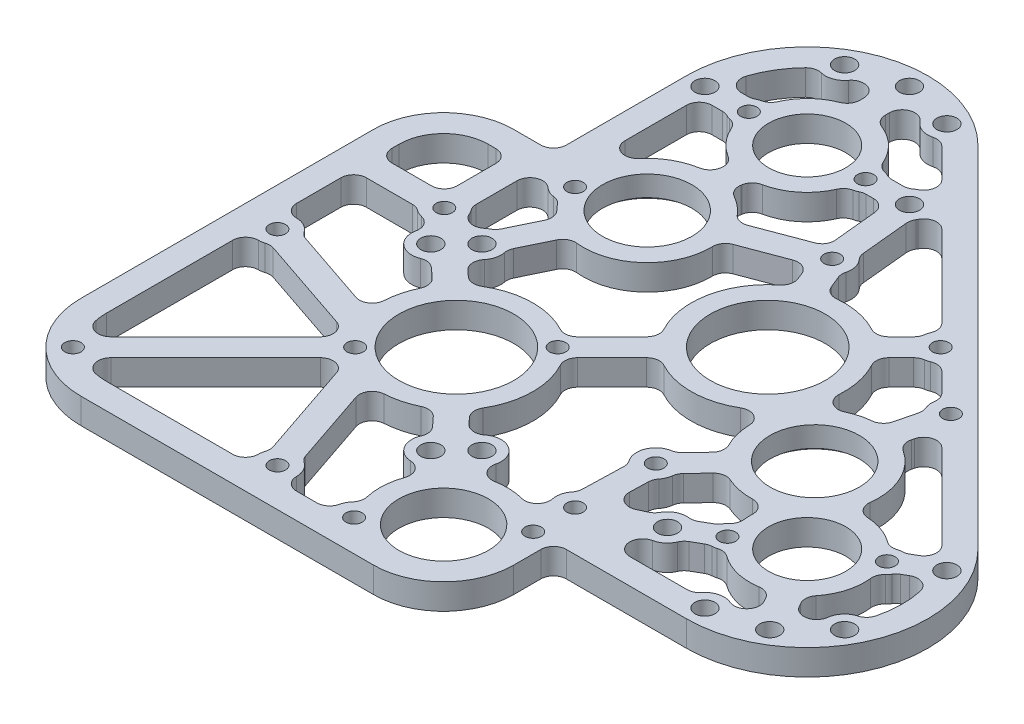
from build123d import *

# Parameters (mm, degrees)
BOSS_EXTRUDE1_DEPTH              = 6.35
SKETCH2_W                        = 83.815021508
SKETCH2_H                        = 6.35
BOSS_EXTRUDE2_DEPTH              = 27.309978492
SKETCH3_W                        = 111.125
SKETCH3_H                        = 6.35
BOSS_EXTRUDE3_DEPTH              = 27.309978492
CUT_EXTRUDE1_DEPTH               = 7.35
CUT_EXTRUDE2_DEPTH               = 7.35
CUT_EXTRUDE3_DEPTH               = 7.35
CUT_EXTRUDE4_DEPTH               = 7.35
CUT_EXTRUDE5_DEPTH               = 7.35
CUT_EXTRUDE6_DEPTH               = 7.35
CUT_EXTRUDE7_DEPTH               = 7.35
CUT_EXTRUDE8_DEPTH               = 7.35
CUT_EXTRUDE9_DEPTH               = 7.35
CUT_EXTRUDE10_DEPTH              = 7.35
CUT_EXTRUDE11_DEPTH              = 7.35
CUT_EXTRUDE12_DEPTH              = 7.35
CUT_EXTRUDE13_DEPTH              = 7.35
SKETCH17_W                       = 16.166007452
SKETCH17_H                       = 16.00062303
CUT_EXTRUDE14_DEPTH              = 7.35
CUT_EXTRUDE15_DEPTH              = 7.35
CUT_EXTRUDE16_DEPTH              = 7.35
CUT_EXTRUDE17_DEPTH              = 7.35
CUT_EXTRUDE18_DEPTH              = 7.35
CUT_EXTRUDE19_DEPTH              = 1.27
F_7_8_0_875_DIAMETER_HOLE1_D     = 22.225
F_7_8_0_875_DIAMETER_HOLE1_DEPTH = 5.08
HOLE1_D                          = 19.177
HOLE1_DEPTH                      = 6.35
F_9_0_196_DIAMETER_HOLE1_D       = 4.9784
F_9_0_196_DIAMETER_HOLE1_DEPTH   = 6.35
F_21_0_159_DIAMETER_HOLE1_D      = 4.0386
F_21_0_159_DIAMETER_HOLE1_DEPTH  = 5.08
F_21_0_159_DIAMETER_HOLE2_D      = 4.0386
F_21_0_159_DIAMETER_HOLE2_DEPTH  = 6.35
F_7_8_0_875_DIAMETER_HOLE2_D     = 22.225
F_7_8_0_875_DIAMETER_HOLE2_DEPTH = 6.35
HOLE2_D                          = 28.575
HOLE2_DEPTH                      = 6.35
F_1_12_TAPPED_HOLE1_D            = 22.225
F_1_12_TAPPED_HOLE1_DEPTH        = 6.35
F_1_12_TAPPED_HOLE1_CBORE_D      = 25.4
F_1_12_TAPPED_HOLE1_CBORE_DEPTH  = 1.27
FILLET1_R                        = 3.175
FILLET2_R                        = 11.061747228
FILLET3_R                        = 17.411747228
FILLET4_R                        = 21.022692091
F_21_0_159_DIAMETER_HOLE3_D      = 4.0386


with BuildPart() as part:
    # Sketch1 → Boss-Extrude1 (new body)
    with BuildSketch(Plane(origin=(0, 3.175, 0), x_dir=(1, 0, 0), z_dir=(0, 1, 0))):
        with BuildLine():
            Line((-29.840021508, 86.969452862), (-29.840021508, -29.840021508))
            Line((-29.840021508, -29.840021508), (86.969452862, -29.840021508))
            ThreePointArc((86.969452862, -29.840021508), (114.685838837, -11.320524479), (108.182656297, 21.373181928))
            Line((108.182656297, 21.373181928), (21.373181928, 108.182656297))
            ThreePointArc((21.373181928, 108.182656297), (-11.320524479, 114.685838837), (-29.840021508, 86.969452862))
        make_face()
    extrude(amount=-BOSS_EXTRUDE1_DEPTH)

    # Sketch2 → Boss-Extrude2 (add)
    with BuildSketch(Plane.XY.offset(29.840021508)):
        with Locations((12.067489246, 0)):
            Rectangle(SKETCH2_W, SKETCH2_H)
    extrude(amount=BOSS_EXTRUDE2_DEPTH)

    # Sketch3 → Boss-Extrude3 (add)
    with BuildSketch(Plane.ZY.offset(29.840021508)):
        with Locations((1.5875, 0)):
            Rectangle(SKETCH3_W, SKETCH3_H)
    extrude(amount=BOSS_EXTRUDE3_DEPTH)

    # Sketch4 → Cut-Extrude1 (cut, through all)
    with BuildSketch(Plane(origin=(0, 3.175, 0), x_dir=(-1, 0, 0), z_dir=(0, 1, 0))):
        with BuildLine():
            Line((-29.065314853, -83.745476551), (-30.455840544, -69.522624049))
            ThreePointArc((-30.455840544, -69.522624049), (-32.264427746, -66.824529621), (-31.922480515, -63.594394438))
            Line((-31.922480515, -63.594394438), (-34.508853412, -57.259190575))
            ThreePointArc((-34.508853412, -57.259190575), (-42.433061391, -57.343409563), (-49.705896748, -54.196024809))
            Line((-49.705896748, -54.196024809), (-55.38295153, -59.87307959))
            ThreePointArc((-55.38295153, -59.87307959), (-55.727962262, -61.935940392), (-56.923524748, -63.652057356))
            Line((-56.923524748, -63.652057356), (-34.906645585, -85.668936518))
            ThreePointArc((-34.906645585, -85.668936518), (-32.152081027, -86.557725422), (-29.82094033, -84.842104637))
            ThreePointArc((-29.82094033, -84.842104637), (-29.481648445, -84.267248015), (-29.065314853, -83.745476551))
        make_face()
    extrude(amount=-CUT_EXTRUDE1_DEPTH, mode=Mode.SUBTRACT)

    # Sketch5 → Cut-Extrude2 (cut, through all)
    with BuildSketch(Plane(origin=(0, 3.175, 0), x_dir=(-1, 0, 0), z_dir=(0, 1, 0))):
        with BuildLine():
            Line((-96.684211501, 10.316477055), (-98.336356147, 13.178075522))
            ThreePointArc((-98.336356147, 13.178075522), (-101.722511979, 14.701115781), (-104.238191329, 11.970353917))
            ThreePointArc((-104.238191329, 11.970353917), (-105.912215429, 8.885878174), (-109.244761312, 7.785657634))
            ThreePointArc((-109.244761312, 7.785657634), (-110.566098558, 1.427727994), (-110.10840545, -5.049904169))
            ThreePointArc((-110.10840545, -5.049904169), (-108.295106019, -7.293181843), (-105.414513295, -7.143064889))
            Line((-105.414513295, -7.143064889), (-103.221340735, -5.876836121))
            ThreePointArc((-103.221340735, -5.876836121), (-102.266814576, -4.495799982), (-100.82964184, -3.628092927))
            ThreePointArc((-100.82964184, -3.628092927), (-100.664608822, 3.911306251), (-96.684211501, 10.316477055))
        make_face()
    extrude(amount=-CUT_EXTRUDE2_DEPTH, mode=Mode.SUBTRACT)

    # Sketch6 → Cut-Extrude3 (cut, through all)
    with BuildSketch(Plane(origin=(0, 3.175, 0), x_dir=(-1, 0, 0), z_dir=(0, 1, 0))):
        with BuildLine():
            Line((16.061248626, -10.243963713), (22.052702088, -15.662227437))
            ThreePointArc((22.052702088, -15.662227437), (27.684230049, -14.871040879), (30.058808712, -20.038386379))
            ThreePointArc((30.058808712, -20.038386379), (30.496077117, -22.417536581), (32.482405731, -23.798137167))
            ThreePointArc((32.482405731, -23.798137167), (33.861760631, -24.337429525), (35.008750462, -25.27437697))
            Line((35.008750462, -25.27437697), (50.8, -25.27437697))
            Line((50.8, -25.27437697), (50.8, -6.724757914))
            ThreePointArc((50.8, -6.724757914), (46.591275424, -7.823958996), (43.244919278, -5.04483933))
            Line((43.244919278, -5.04483933), (23.20612022, 1.735140088))
            ThreePointArc((23.20612022, 1.735140088), (20.412532978, 1.359425204), (19.018755694, -1.090610762))
            ThreePointArc((19.018755694, -1.090610762), (18.127262434, -5.8570348), (16.061248626, -10.243963713))
        make_face()
    extrude(amount=-CUT_EXTRUDE3_DEPTH, mode=Mode.SUBTRACT)

    # Sketch7 → Cut-Extrude4 (cut, through all)
    with BuildSketch(Plane(origin=(0, 3.175, 0), x_dir=(-1, 0, 0), z_dir=(0, 1, 0))):
        with BuildLine():
            Line((-24.259462149, -96.316119955), (-15.54353696, -105.032045144))
            ThreePointArc((-15.54353696, -105.032045144), (-12.080764428, -104.268175897), (-9.049978492, -106.108998118))
            ThreePointArc((-9.049978492, -106.108998118), (-5.505955335, -107.216067589), (-3.334978492, -104.203998118))
            Line((-3.334978492, -104.203998118), (-3.334978492, -100.899708827))
            ThreePointArc((-3.334978492, -100.899708827), (-9.984690796, -97.342865241), (-13.897312756, -90.896067632))
            ThreePointArc((-13.897312756, -90.896067632), (-15.575806101, -90.863204873), (-17.092979596, -90.144452862))
            Line((-17.092979596, -90.144452862), (-22.010220578, -90.144452862))
            ThreePointArc((-22.010220578, -90.144452862), (-22.669959149, -90.754845106), (-23.432630268, -91.230414699))
            ThreePointArc((-23.432630268, -91.230414699), (-25.148251052, -93.561555396), (-24.259462149, -96.316119955))
        make_face()
    extrude(amount=-CUT_EXTRUDE4_DEPTH, mode=Mode.SUBTRACT)

    # Sketch8 → Cut-Extrude5 (cut, through all)
    with BuildSketch(Plane(origin=(0, 3.175, 0), x_dir=(-1, 0, 0), z_dir=(0, 1, 0))):
        with BuildLine():
            Line((-28.629907712, -54.859086941), (-25.869683695, -61.620131289))
            Line((-25.869683695, -61.620131289), (-9.958043734, -55.623628588))
            ThreePointArc((-9.958043734, -55.623628588), (-5.003627435, -41.400778281), (9.599912876, -37.716715024))
            Line((9.599912876, -37.716715024), (14.64981546, -27.222026966))
            ThreePointArc((14.64981546, -27.222026966), (14.863395085, -23.129813767), (18.176462317, -20.718297514))
            Line((18.176462317, -20.718297514), (11.802062224, -14.953722856))
            ThreePointArc((11.802062224, -14.953722856), (0.478055111, -19.044000717), (-11.036913891, -15.527041951))
            Line((-11.036913891, -15.527041951), (-23.141940906, -27.632068966))
            ThreePointArc((-23.141940906, -27.632068966), (-19.994556151, -42.433061391), (-28.629907712, -54.859086941))
        make_face()
    extrude(amount=-CUT_EXTRUDE5_DEPTH, mode=Mode.SUBTRACT)

    # Sketch9 → Cut-Extrude6 (cut, through all)
    with BuildSketch(Plane(origin=(0, 3.175, 0), x_dir=(-1, 0, 0), z_dir=(0, 1, 0))):
        with BuildLine():
            Line((-66.570306617, 23.490021508), (-82.540129409, 23.490021508))
            ThreePointArc((-82.540129409, 23.490021508), (-85.134980242, 20.845011103), (-88.84025965, 20.860353917))
            ThreePointArc((-88.84025965, 20.860353917), (-92.463008471, 20.047092624), (-92.837094833, 16.353075522))
            Line((-92.837094833, 16.353075522), (-91.184950187, 13.491477055))
            ThreePointArc((-91.184950187, 13.491477055), (-83.647710894, 13.73601685), (-77.035883168, 10.109240047))
            ThreePointArc((-77.035883168, 10.109240047), (-75.565840448, 10.920014619), (-73.892564989, 11.056140451))
            Line((-73.892564989, 11.056140451), (-69.634088137, 13.514773208))
            ThreePointArc((-69.634088137, 13.514773208), (-68.334217118, 15.91339416), (-65.931147012, 17.205021508))
            ThreePointArc((-65.931147012, 17.205021508), (-63.411598416, 20.63624962), (-66.570306617, 23.490021508))
        make_face()
    extrude(amount=-CUT_EXTRUDE6_DEPTH, mode=Mode.SUBTRACT)

    # Sketch10 → Cut-Extrude7 (cut, through all)
    with BuildSketch(Plane(origin=(0, 3.175, 0), x_dir=(-1, 0, 0), z_dir=(0, 1, 0))):
        with BuildLine():
            Line((-60.582930959, -6.529869086), (-54.504223769, -0.14881941))
            ThreePointArc((-54.504223769, -0.14881941), (-54.153577144, 2.061993213), (-52.831648467, 3.868412347))
            Line((-52.831648467, 3.868412347), (-52.670582669, 9.638745034))
            ThreePointArc((-52.670582669, 9.638745034), (-54.090630257, 12.374049221), (-57.163109223, 12.615497253))
            Line((-57.163109223, 12.615497253), (-60.424579656, 11.126279242))
            ThreePointArc((-60.424579656, 11.126279242), (-62.790235694, 8.306874688), (-66.459088137, 8.015511894))
            Line((-66.459088137, 8.015511894), (-70.717564989, 5.556879137))
            ThreePointArc((-70.717564989, 5.556879137), (-71.672091147, 4.175842998), (-73.109263883, 3.308135943))
            ThreePointArc((-73.109263883, 3.308135943), (-72.69360414, -0.736866294), (-73.434293106, -4.735140418))
            ThreePointArc((-73.434293106, -4.735140418), (-66.816865189, -4.259479304), (-60.582930959, -6.529869086))
        make_face()
    extrude(amount=-CUT_EXTRUDE7_DEPTH, mode=Mode.SUBTRACT)

    # Sketch11 → Cut-Extrude8 (cut, through all)
    with BuildSketch(Plane(origin=(0, 3.175, 0), x_dir=(-1, 0, 0), z_dir=(0, 1, 0))):
        with BuildLine():
            Line((36.127307909, 50.8), (0.374757914, 50.8))
            ThreePointArc((0.374757914, 50.8), (1.560030882, 48.135772743), (0.970199293, 45.280063098))
            Line((0.970199293, 45.280063098), (9.398704369, 20.368907892))
            ThreePointArc((9.398704369, 20.368907892), (11.683715037, 18.294780227), (14.651287711, 19.141415771))
            Line((14.651287711, 19.141415771), (40.659943467, 45.150071528))
            ThreePointArc((40.659943467, 45.150071528), (41.454977614, 48.310792739), (39.046574871, 50.506660245))
            ThreePointArc((39.046574871, 50.506660245), (37.594291874, 50.726480873), (36.127307909, 50.8))
        make_face()
    extrude(amount=-CUT_EXTRUDE8_DEPTH, mode=Mode.SUBTRACT)

    # Sketch12 → Cut-Extrude9 (cut, through all)
    with BuildSketch(Plane(origin=(0, 3.175, 0), x_dir=(-1, 0, 0), z_dir=(0, 1, 0))):
        with BuildLine():
            Line((28.283992548, -43.369863902), (28.283992548, -31.999134884))
            ThreePointArc((28.283992548, -31.999134884), (27.576476206, -31.207541777), (27.061909479, -30.278876011))
            ThreePointArc((27.061909479, -30.278876011), (24.888201007, -28.415273374), (22.09831246, -29.059125223))
            ThreePointArc((22.09831246, -29.059125223), (21.282584128, -29.606777194), (20.371835564, -29.975385994))
            Line((20.371835564, -29.975385994), (15.32193298, -40.470074052))
            ThreePointArc((15.32193298, -40.470074052), (17.363374739, -42.322013743), (19.053717301, -44.499146514))
            ThreePointArc((19.053717301, -44.499146514), (21.142986813, -44.662533252), (22.959852825, -45.706918341))
            ThreePointArc((22.959852825, -45.706918341), (26.385140341, -46.277108613), (28.283992548, -43.369863902))
        make_face()
    extrude(amount=-CUT_EXTRUDE9_DEPTH, mode=Mode.SUBTRACT)

    # Sketch13 → Cut-Extrude10 (cut, through all)
    with BuildSketch(Plane(origin=(0, 3.175, 0), x_dir=(-1, 0, 0), z_dir=(0, 1, 0))):
        with BuildLine():
            Line((-69.682869776, -35.842744593), (-71.808502621, -44.395531336))
            ThreePointArc((-71.808502621, -44.395531336), (-70.997177713, -46.713307725), (-71.448414159, -49.127167945))
            Line((-71.448414159, -49.127167945), (-63.652057356, -56.923524748))
            ThreePointArc((-63.652057356, -56.923524748), (-61.935940392, -55.727962262), (-59.87307959, -55.38295153))
            Line((-59.87307959, -55.38295153), (-54.196024809, -49.705896748))
            ThreePointArc((-54.196024809, -49.705896748), (-56.999426765, -43.855246072), (-57.676876773, -37.403096248))
            ThreePointArc((-57.676876773, -37.403096248), (-59.059742549, -34.566475429), (-62.206140186, -34.323746484))
            ThreePointArc((-62.206140186, -34.323746484), (-65.851895027, -35.539085199), (-69.682869776, -35.842744593))
        make_face()
    extrude(amount=-CUT_EXTRUDE10_DEPTH, mode=Mode.SUBTRACT)

    # Sketch14 → Cut-Extrude11 (cut, through all)
    with BuildSketch(Plane(origin=(0, 3.175, 0), x_dir=(-1, 0, 0), z_dir=(0, 1, 0))):
        with BuildLine():
            Line((-46.137781027, 16.099178917), (-46.484120732, 3.691235453))
            ThreePointArc((-46.484120732, 3.691235453), (-45.360281844, -1.599097167), (-49.906493822, -4.528702895))
            Line((-49.906493822, -4.528702895), (-55.985201012, -10.90975257))
            ThreePointArc((-55.985201012, -10.90975257), (-53.923588695, -15.048445679), (-53.142004959, -19.605654568))
            ThreePointArc((-53.142004959, -19.605654568), (-51.509237321, -22.306174012), (-48.353766254, -22.26448742))
            ThreePointArc((-48.353766254, -22.26448742), (-37.863039079, -19.636038928), (-27.632068966, -23.141940906))
            Line((-27.632068966, -23.141940906), (-15.527041951, -11.036913891))
            ThreePointArc((-15.527041951, -11.036913891), (-19.045881779, 0.396089964), (-15.054754337, 11.672911884))
            Line((-15.054754337, 11.672911884), (-20.779684581, 17.894971134))
            ThreePointArc((-20.779684581, 17.894971134), (-26.564647889, 14.432099877), (-30.015464801, 20.224261861))
            ThreePointArc((-30.015464801, 20.224261861), (-30.774617983, 23.176969436), (-33.670909908, 24.12896138))
            ThreePointArc((-33.670909908, 24.12896138), (-37.161505216, 23.874529407), (-40.623023006, 24.391139341))
            ThreePointArc((-40.623023006, 24.391139341), (-43.614580975, 23.63038548), (-44.545986232, 20.687487289))
            ThreePointArc((-44.545986232, 20.687487289), (-44.713076202, 18.175184646), (-46.137781027, 16.099178917))
        make_face()
    extrude(amount=-CUT_EXTRUDE11_DEPTH, mode=Mode.SUBTRACT)

    # Sketch15 → Cut-Extrude12 (cut, through all)
    with BuildSketch(Plane(origin=(0, 3.175, 0), x_dir=(-1, 0, 0), z_dir=(0, 1, 0))):
        with BuildLine():
            Line((-0.906158558, -72.701451195), (-0.071396741, -67.891668141))
            ThreePointArc((-0.071396741, -67.891668141), (-4.402116989, -65.341644955), (-7.718709476, -61.565672182))
            Line((-7.718709476, -61.565672182), (-22.06510912, -66.97229428))
            ThreePointArc((-22.06510912, -66.97229428), (-22.927838988, -67.463250121), (-23.59679754, -68.196622414))
            ThreePointArc((-23.59679754, -68.196622414), (-23.958933452, -69.120850765), (-24.017969044, -70.111736864))
            Line((-24.017969044, -70.111736864), (-22.68025088, -83.794452862))
            Line((-22.68025088, -83.794452862), (-17.092979596, -83.794452862))
            ThreePointArc((-17.092979596, -83.794452862), (-15.575806101, -83.07570085), (-13.897312756, -83.042838091))
            ThreePointArc((-13.897312756, -83.042838091), (-9.058243355, -75.791190981), (-0.906158558, -72.701451195))
        make_face()
    extrude(amount=-CUT_EXTRUDE12_DEPTH, mode=Mode.SUBTRACT)

    # Sketch16 → Cut-Extrude13 (cut, through all)
    with BuildSketch(Plane(origin=(0, 3.175, 0), x_dir=(-1, 0, 0), z_dir=(0, 1, 0))):
        with BuildLine():
            Line((23.490021508, -83.794452862), (23.490021508, -65.348236852))
            ThreePointArc((23.490021508, -65.348236852), (21.400292446, -62.36447882), (17.881950962, -63.308434725))
            ThreePointArc((17.881950962, -63.308434725), (12.64032701, -67.394997399), (6.185075685, -68.977510107))
            Line((6.185075685, -68.977510107), (5.350313868, -73.787293162))
            ThreePointArc((5.350313868, -73.787293162), (10.518693118, -77.477423105), (13.577354482, -83.042833577))
            ThreePointArc((13.577354482, -83.042833577), (15.255836108, -83.075703561), (16.77299808, -83.794452862))
            Line((16.77299808, -83.794452862), (23.490021508, -83.794452862))
        make_face()
    extrude(amount=-CUT_EXTRUDE13_DEPTH, mode=Mode.SUBTRACT)

    # Sketch17 → Cut-Extrude14 (cut, through all)
    with BuildSketch(Plane(origin=(0, 3.175, 0), x_dir=(-1, 0, 0), z_dir=(0, 1, 0))):
        with Locations((42.716996274, -39.624688485)):
            Rectangle(SKETCH17_W, SKETCH17_H)
    extrude(amount=-CUT_EXTRUDE14_DEPTH, mode=Mode.SUBTRACT)

    # Sketch18 → Cut-Extrude15 (cut, through all)
    with BuildSketch(Plane(origin=(0, 3.175, 0), x_dir=(-1, 0, 0), z_dir=(0, 1, 0))):
        with BuildLine():
            Line((-15.828635929, 21.89226287), (-10.381830318, 15.972479433))
            ThreePointArc((-10.381830318, 15.972479433), (-5.93499586, 18.101887309), (-1.090610762, 19.018755694))
            ThreePointArc((-1.090610762, 19.018755694), (1.359425204, 20.412532978), (1.735140088, 23.20612022))
            Line((1.735140088, 23.20612022), (-5.04483933, 43.244919278))
            ThreePointArc((-5.04483933, 43.244919278), (-7.823958996, 46.591275424), (-6.724757914, 50.8))
            Line((-6.724757914, 50.8), (-19.383870504, 50.8))
            ThreePointArc((-19.383870504, 50.8), (-19.490260419, 47.566496518), (-21.638090632, 45.147056716))
            ThreePointArc((-21.638090632, 45.147056716), (-20.688290752, 39.772978414), (-21.61457063, 34.394796286))
            ThreePointArc((-21.61457063, 34.394796286), (-21.268439906, 31.567704045), (-18.794900521, 30.155662993))
            ThreePointArc((-18.794900521, 30.155662993), (-14.567545862, 27.009040443), (-15.828635929, 21.89226287))
        make_face()
    extrude(amount=-CUT_EXTRUDE15_DEPTH, mode=Mode.SUBTRACT)

    # Sketch19 → Cut-Extrude16 (cut, through all)
    with BuildSketch(Plane(origin=(0, 3.175, 0), x_dir=(-1, 0, 0), z_dir=(0, 1, 0))):
        with BuildLine():
            Line((-102.923377056, -17.652205047), (-81.891009315, -38.684572789))
            ThreePointArc((-81.891009315, -38.684572789), (-78.796315451, -39.49871685), (-76.56468078, -37.20529858))
            Line((-76.56468078, -37.20529858), (-75.845398786, -34.31116495))
            ThreePointArc((-75.845398786, -34.31116495), (-83.799073427, -25.758945796), (-83.749661029, -14.079949641))
            ThreePointArc((-83.749661029, -14.079949641), (-90.790539349, -13.927038974), (-96.903022555, -10.429197031))
            ThreePointArc((-96.903022555, -10.429197031), (-98.373065275, -11.239971603), (-100.046340735, -11.376097435))
            Line((-100.046340735, -11.376097435), (-102.265813026, -12.65751036))
            ThreePointArc((-102.265813026, -12.65751036), (-103.826150461, -14.992720357), (-102.923377056, -17.652205047))
        make_face()
    extrude(amount=-CUT_EXTRUDE16_DEPTH, mode=Mode.SUBTRACT)

    # Sketch20 → Cut-Extrude17 (cut, through all)
    with BuildSketch(Plane(origin=(0, 3.175, 0), x_dir=(-1, 0, 0), z_dir=(0, 1, 0))):
        with BuildLine():
            Line((3.015021508, -100.899708827), (3.015021508, -104.203998118))
            ThreePointArc((3.015021508, -104.203998118), (5.185998351, -107.216067589), (8.730021508, -106.108998118))
            ThreePointArc((8.730021508, -106.108998118), (11.722006776, -104.274775817), (15.15818644, -104.988229821))
            ThreePointArc((15.15818644, -104.988229821), (19.481462882, -100.14276986), (22.323905105, -94.304129296))
            ThreePointArc((22.323905105, -94.304129296), (21.87518057, -91.454744128), (19.305455616, -90.144452862))
            Line((19.305455616, -90.144452862), (16.77299808, -90.144452862))
            ThreePointArc((16.77299808, -90.144452862), (15.255836108, -90.863202162), (13.577354482, -90.896072146))
            ThreePointArc((13.577354482, -90.896072146), (9.664732108, -97.342866855), (3.015021508, -100.899708827))
        make_face()
    extrude(amount=-CUT_EXTRUDE17_DEPTH, mode=Mode.SUBTRACT)

    # Sketch21 → Cut-Extrude18 (cut, through all)
    with BuildSketch(Plane.XZ.offset(3.175)):
        with BuildLine():
            Line((-45.280063098, 0.970199293), (-20.368907892, 9.398704369))
            ThreePointArc((-20.368907892, 9.398704369), (-18.294780227, 11.683715037), (-19.141415771, 14.651287711))
            Line((-19.141415771, 14.651287711), (-45.150071528, 40.659943467))
            ThreePointArc((-45.150071528, 40.659943467), (-48.310792739, 41.454977614), (-50.506660245, 39.046574871))
            ThreePointArc((-50.506660245, 39.046574871), (-50.726480873, 37.594291874), (-50.8, 36.127307909))
            Line((-50.8, 36.127307909), (-50.8, 0.374757914))
            ThreePointArc((-50.8, 0.374757914), (-48.135772743, 1.560030882), (-45.280063098, 0.970199293))
        make_face()
    extrude(amount=-CUT_EXTRUDE18_DEPTH, mode=Mode.SUBTRACT)

    # Sketch22 → Cut-Extrude19 (cut)
    with BuildSketch(Plane.XZ.offset(3.175)):
        with BuildLine():
            ThreePointArc((-19.060256379, -46.501483041), (-22.428083199, -48.464238508), (-20.5562424, -51.88343118))
            ThreePointArc((-20.5562424, -51.88343118), (-19.046655622, -52.888896379), (-18.333858257, -54.556749016))
            ThreePointArc((-18.333858257, -54.556749016), (6.519492488, -56.510612691), (-15.777082149, -45.358510379))
            ThreePointArc((-15.777082149, -45.358510379), (-17.24833626, -46.419276067), (-19.060256379, -46.501483041))
        make_face()
    extrude(amount=-CUT_EXTRUDE19_DEPTH, mode=Mode.SUBTRACT)

    # 7/8 (0.875) Diameter Hole1
    with Locations(Plane(origin=(0, -1.905, 0), x_dir=(-1, 0, 0), z_dir=(0, -1, 0))):
        with Locations((5.716598231, 53.109424089)):
            Hole(F_7_8_0_875_DIAMETER_HOLE1_D / 2, depth=F_7_8_0_875_DIAMETER_HOLE1_DEPTH)

    # Hole1
    with Locations(Plane(origin=(0, -3.175, 0), x_dir=(-1, 0, 0), z_dir=(0, -1, 0))):
        with Locations((-86.969452862, 0.159978492), (-0.159978492, 86.969452862)):
            Hole(HOLE1_D / 2, depth=HOLE1_DEPTH)

    # #9 (0.196) Diameter Hole1
    with Locations(Plane(origin=(0, -3.175, 0), x_dir=(-1, 0, 0), z_dir=(0, -1, 0))):
        with Locations((-25.4, -19.05), (-19.05, -25.4), (19.05, 25.4), (25.4, 19.05), (-0.159978492, 112.369452862), (12.540021508, 108.966498118), (-86.969452862, -25.240021508), (-99.669452862, -21.837066764), (-25.559978492, 86.969452862), (-108.966498118, -12.540021508), (-108.966498118, 12.859978492), (-64.972407605, -12.540021508), (-12.859978492, 108.966498118), (25.240021508, 86.969452862)):
            Hole(F_9_0_196_DIAMETER_HOLE1_D / 2, depth=F_9_0_196_DIAMETER_HOLE1_DEPTH)

    # #21 (0.159) Diameter Hole1
    with Locations(Plane(origin=(0, -1.905, 0), x_dir=(-1, 0, 0), z_dir=(0, -1, 0))):
        with Locations((19.73614324, 49.2125)):
            Hole(F_21_0_159_DIAMETER_HOLE1_D / 2, depth=F_21_0_159_DIAMETER_HOLE1_DEPTH)

    # #21 (0.159) Diameter Hole2
    with Locations(Plane(origin=(0, -3.175, 0), x_dir=(-1, 0, 0), z_dir=(0, -1, 0))):
        with Locations((-49.2125, -30.145955364), (-23.914005544, -49.33055018), (-49.2125, -19.73614324), (47.625, -47.625), (-99.526821216, 7.409978492), (14.340021508, 86.969452862), (-14.660003024, 86.969452862), (-74.412084507, -7.090021508), (47.625, 3.175), (-3.175, -47.625), (-60.138073453, 60.138073453), (-27.641308945, 65.680773176), (-49.756929494, -0.231448023), (-75.745946174, 47.07469996), (31.458992548, 28.44937697)):
            Hole(F_21_0_159_DIAMETER_HOLE2_D / 2, depth=F_21_0_159_DIAMETER_HOLE2_DEPTH)

    # 7/8 (0.875) Diameter Hole2
    with Locations(Plane(origin=(0, -3.175, 0), x_dir=(-1, 0, 0), z_dir=(0, -1, 0))):
        with Locations((-36.563252772, -39.738252772)):
            Hole(F_7_8_0_875_DIAMETER_HOLE2_D / 2, depth=F_7_8_0_875_DIAMETER_HOLE2_DEPTH)

    # Hole2
    with Locations(Plane(origin=(0, 3.175, 0), x_dir=(1, 0, 0), z_dir=(0, 1, 0))):
        with Locations((38.668982857, 38.668982857), (0, 0)):
            Hole(HOLE2_D / 2, depth=HOLE2_DEPTH)

    # 1-12 Tapped Hole1
    with Locations(Plane(origin=(0, -3.175, 0), x_dir=(-1, 0, 0), z_dir=(0, -1, 0))):
        with Locations((-69.012545655, 19.981903172)):
            CounterBoreHole(F_1_12_TAPPED_HOLE1_D / 2, F_1_12_TAPPED_HOLE1_CBORE_D / 2, F_1_12_TAPPED_HOLE1_CBORE_DEPTH, depth=F_1_12_TAPPED_HOLE1_DEPTH)

    # Fillet1
    fillet1_edges = [part.edges().sort_by_distance(p)[0] for p in [
        (-43.244919278, 0, -5.04483933),
        (-50.8, 0, -6.724757914),
        (-50.8, 0, -25.27437697),
        (-35.008750462, 0, -25.27437697),
        (-22.052702088, 0, -15.662227437),
        (-16.061248626, 0, -10.243963713),
        (22.010220578, 0, -90.144452862),
        (17.092979596, 0, -90.144452862),
        (13.897312756, 0, -90.896067632),
        (3.334978492, 0, -100.899708827),
        (15.54353696, 0, -105.032045144),
        (28.629907712, 0, -54.859086941),
        (23.141940906, 0, -27.632068966),
        (11.036913891, 0, -15.527041951),
        (-11.802062224, 0, -14.953722856),
        (-18.176462317, 0, -20.718297514),
        (-14.64981546, 0, -27.222026966),
        (53.975, 0, 29.840021508),
        (-9.599912876, 0, -37.716715024),
        (9.958043734, 0, -55.623628588),
        (25.869683695, 0, -61.620131289),
        (69.634088137, 0, 13.514773208),
        (73.892564989, 0, 11.056140451),
        (77.035883168, 0, 10.109240047),
        (91.184950187, 0, 13.491477055),
        (82.540129409, 0, 23.490021508),
        (73.434293106, 0, -4.735140418),
        (73.109263883, 0, 3.308135943),
        (70.717564989, 0, 5.556879137),
        (66.459088137, 0, 8.015511894),
        (60.424579656, 0, 11.126279242),
        (52.831648467, 0, 3.868412347),
        (54.504223769, 0, -0.14881941),
        (60.582930959, 0, -6.529869086),
        (-0.970199293, 0, 45.280063098),
        (-0.374757914, 0, 50.8),
        (-19.053717301, 0, -44.499146514),
        (-15.32193298, 0, -40.470074052),
        (-20.371835564, 0, -29.975385994),
        (-28.283992548, 0, -31.999134884),
        (-29.840021508, 0, -53.975),
        (54.196024809, 0, -49.705896748),
        (59.87307959, 0, -55.38295153),
        (63.652057356, 0, -56.923524748),
        (71.448414159, 0, -49.127167945),
        (71.808502621, 0, -44.395531336),
        (69.682869776, 0, -35.842744593),
        (20.779684581, 0, 17.894971134),
        (15.054754337, 0, 11.672911884),
        (15.527041951, 0, -11.036913891),
        (27.632068966, 0, -23.141940906),
        (55.985201012, 0, -10.90975257),
        (49.906493822, 0, -4.528702895),
        (46.484120732, 0, 3.691235453),
        (46.137781027, 0, 16.099178917),
        (0.906158558, 0, -72.701451195),
        (13.897312756, 0, -83.042838091),
        (17.092979596, 0, -83.794452862),
        (22.68025088, 0, -83.794452862),
        (7.718709476, 0, -61.565672182),
        (0.071396741, 0, -67.891668141),
        (-23.490021508, 0, -83.794452862),
        (-16.77299808, 0, -83.794452862),
        (-13.577354482, 0, -83.042833577),
        (-5.350313868, 0, -73.787293162),
        (-6.185075685, 0, -68.977510107),
        (-50.8, 0, -31.62437697),
        (-34.633992548, 0, -47.625),
        (-34.633992548, 0, -31.62437697),
        (21.638090632, 0, 45.147056716),
        (19.383870504, 0, 50.8),
        (6.724757914, 0, 50.8),
        (5.04483933, 0, 43.244919278),
        (10.381830318, 0, 15.972479433),
        (15.828635929, 0, 21.89226287),
        (100.046340735, 0, -11.376097435),
        (96.903022555, 0, -10.429197031),
        (83.749661029, 0, -14.079949641),
        (75.845398786, 0, -34.31116495),
        (56.923524748, 0, -63.652057356),
        (55.38295153, 0, -59.87307959),
        (49.705896748, 0, -54.196024809),
        (-3.015021508, 0, -100.899708827),
        (-13.577354482, 0, -90.896072146),
        (34.508853412, 0, -57.259190575),
        (-16.77299808, 0, -90.144452862),
        (-15.15818644, 0, -104.988229821),
        (31.922480515, 0, -63.594394438),
        (30.455840544, 0, -69.522624049),
        (29.065314853, 0, -83.745476551),
        (-45.280063098, 0, 0.970199293),
        (-50.8, 0, 0.374757914),
        (96.684211501, 0, 10.316477055),
        (100.82964184, 0, -3.628092927),
        (103.221340735, 0, -5.876836121),
        (109.244761312, 0, 7.785657634),
    ]]
    fillet(fillet1_edges, radius=FILLET1_R)

    # Fillet2
    fillet2_edges = [part.edges().sort_by_distance(p)[0] for p in [
        (-50.8, 0, -47.625),
    ]]
    fillet(fillet2_edges, radius=FILLET2_R)

    # Fillet3
    fillet3_edges = [part.edges().sort_by_distance(p)[0] for p in [
        (53.975, 0, 57.15),
        (-57.15, 0, -53.975),
    ]]
    fillet(fillet3_edges, radius=FILLET3_R)

    # Fillet4
    fillet4_edges = [part.edges().sort_by_distance(p)[0] for p in [
        (-57.15, 0, 57.15),
    ]]
    fillet(fillet4_edges, radius=FILLET4_R)

    # #21 (0.159) Diameter Hole3 (through all)
    with Locations(Plane(origin=(0, 3.175, 0), x_dir=(1, 0, 0), z_dir=(0, 1, 0))):
        with Locations((12.572358569, 12.572358569), (-12.572358569, -12.572358569)):
            Hole(F_21_0_159_DIAMETER_HOLE3_D / 2)


solid = part.part
